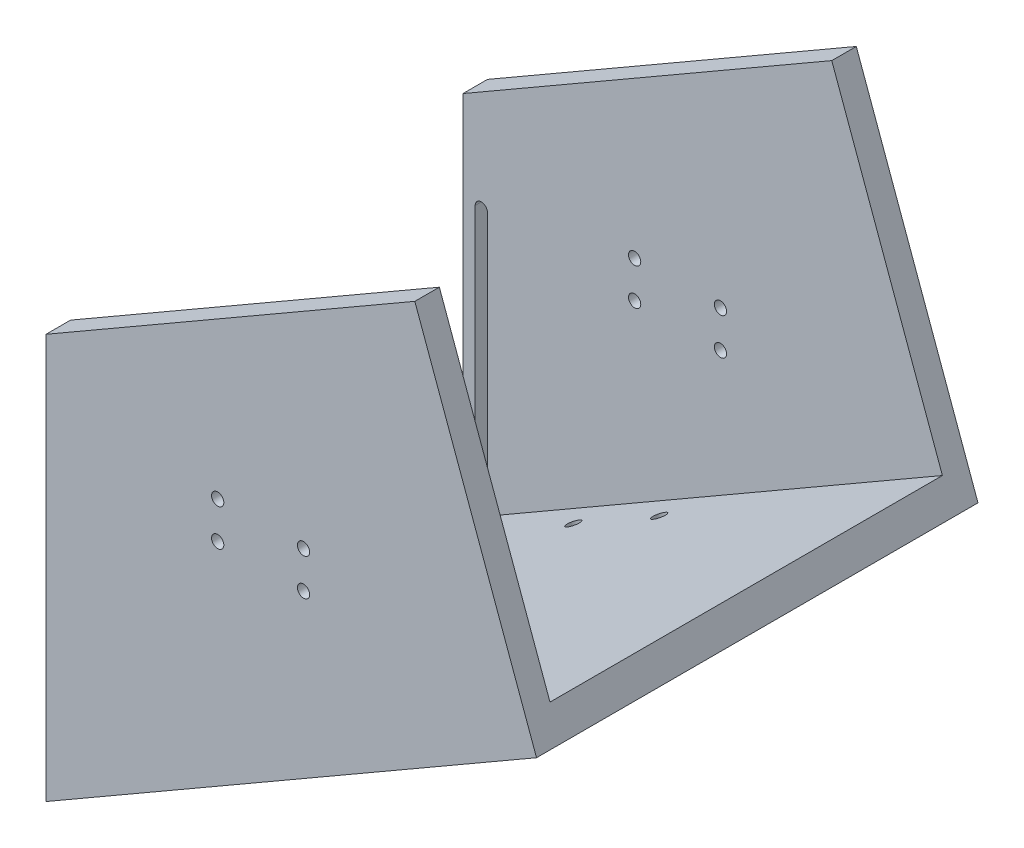
from build123d import *

# Parameters (mm, degrees)
SKETCH1_W            = 50
SKETCH1_H            = 150
SKETCH1_R            = 2.5
BOSS_EXTRUDE1_DEPTH  = 15
BOSS_EXTRUDE2_DEPTH  = 90
SKETCH3_W            = 250
SKETCH3_H            = 15
BOSS_EXTRUDE3_DEPTH  = 150
BOSS_EXTRUDE8_DEPTH  = 10
CUT_EXTRUDE1_DEPTH   = 10
SKETCH10_W           = 115
SKETCH10_H           = 165
BOSS_EXTRUDE12_DEPTH = 15
CUT_EXTRUDE3_DEPTH   = 181
SKETCH13_R           = 2.5
CUT_EXTRUDE4_DEPTH   = 116.470053838
SKETCH14_R           = 2.5
CUT_EXTRUDE5_DEPTH   = 181


with BuildPart() as part:
    # Sketch1 → Boss-Extrude1 (new body)
    with BuildSketch(Plane(origin=(0, 0, 0), x_dir=(1, 0, 0), z_dir=(0, 1, 0))):
        Polygon((0, 90), (0, 75), (50, 75), (50, -75), (0, -75), (0, -90), (250, -90), (250, 90), align=None)
        with Locations((25, 0)):
            Rectangle(SKETCH1_W, SKETCH1_H)
        with Locations((7.5, -67.5)):
            Circle(SKETCH1_R, mode=Mode.SUBTRACT)
        with Locations((42.5, -67.5)):
            Circle(SKETCH1_R, mode=Mode.SUBTRACT)
        with Locations((7.5, 67.5)):
            Circle(SKETCH1_R, mode=Mode.SUBTRACT)
        with Locations((42.5, 67.5)):
            Circle(SKETCH1_R, mode=Mode.SUBTRACT)
    extrude(amount=BOSS_EXTRUDE1_DEPTH)

    # Sketch2 → Boss-Extrude2 (add, symmetric)
    with BuildSketch(Plane.XY):
        Polygon((0, 0), (-200, -115.470053838), (-200, -100.470053838), (0, 15), align=None)
    extrude(amount=BOSS_EXTRUDE2_DEPTH, both=True)

    # Sketch3 → Boss-Extrude3 (add)
    with BuildSketch(Plane(origin=(0, 15, 0), x_dir=(1, 0, 0), z_dir=(0, 1, 0))):
        with Locations((125, 82.5)):
            Rectangle(SKETCH3_W, SKETCH3_H)
        with Locations((125, -82.5)):
            Rectangle(SKETCH3_W, SKETCH3_H)
    extrude(amount=BOSS_EXTRUDE3_DEPTH)

    # Sketch8 → Boss-Extrude8 (add)
    with BuildSketch(Plane.XY.offset(90)):
        Polygon((0, 15), (-200, -100.470053838), (-200, 49.529946162), (0, 165), align=None)
    boss_extrude8 = extrude(amount=-BOSS_EXTRUDE8_DEPTH)

    # Mirror1: Boss-Extrude8 across plane
    add(boss_extrude8.mirror(Plane.XY))

    # Sketch9 → Cut-Extrude1 (cut)
    with BuildSketch(Plane.XY.offset(-75)):
        with BuildLine():
            Line((-190, 12.520327219), (-190, -87.479672781))
            ThreePointArc((-190, -87.479672781), (-192.5, -89.979672781), (-195, -87.479672781))
            Line((-195, -87.479672781), (-195, 12.520327219))
            ThreePointArc((-195, 12.520327219), (-192.5, 15.020327219), (-190, 12.520327219))
        make_face()
    cut_extrude1 = extrude(amount=-CUT_EXTRUDE1_DEPTH, mode=Mode.SUBTRACT)

    # Mirror2: Cut-Extrude1 across plane
    add(cut_extrude1.mirror(Plane.XY), mode=Mode.SUBTRACT)

    # Sketch10 → Boss-Extrude12 (add)
    with BuildSketch(Plane(origin=(250, 0, 0), x_dir=(0, 0, -1), z_dir=(1, 0, 0))):
        with Locations((-32.5, 82.5)):
            Rectangle(SKETCH10_W, SKETCH10_H)
    boss_extrude12 = extrude(amount=-BOSS_EXTRUDE12_DEPTH)

    # Mirror3: Boss-Extrude12 across plane
    add(boss_extrude12.mirror(Plane.XY))

    # Sketch12 → Cut-Extrude3 (cut, through all)
    with BuildSketch(Plane.XY.offset(90)):
        Polygon((0, 165), (250, 165), (250, 0), (0, 0), (-49.62663195, 136.348050685), align=None)
    extrude(amount=-CUT_EXTRUDE3_DEPTH, mode=Mode.SUBTRACT)

    # Sketch13 → Cut-Extrude4 (cut, through all)
    with BuildSketch(Plane(origin=(0, 0, 0), x_dir=(1, 0, 0), z_dir=(0, 1, 0))):
        with Locations((-142.5, 67.5)):
            Circle(SKETCH13_R)
        with Locations((-107.5, 67.5)):
            Circle(SKETCH13_R)
        with Locations((-142.5, -67.5)):
            Circle(SKETCH13_R)
        with Locations((-107.5, -67.5)):
            Circle(SKETCH13_R)
    extrude(amount=-CUT_EXTRUDE4_DEPTH, mode=Mode.SUBTRACT)

    # Sketch14 → Cut-Extrude5 (cut, through all)
    with BuildSketch(Plane(origin=(0, 0, -90), x_dir=(-1, 0, 0), z_dir=(0, 0, -1))):
        with Locations((95, 11.348050685)):
            Circle(SKETCH14_R)
        with Locations((130, 11.348050685)):
            Circle(SKETCH14_R)
        with Locations((95, 26.348050685)):
            Circle(SKETCH14_R)
        with Locations((130, 26.348050685)):
            Circle(SKETCH14_R)
    extrude(amount=-CUT_EXTRUDE5_DEPTH, mode=Mode.SUBTRACT)


solid = part.part
